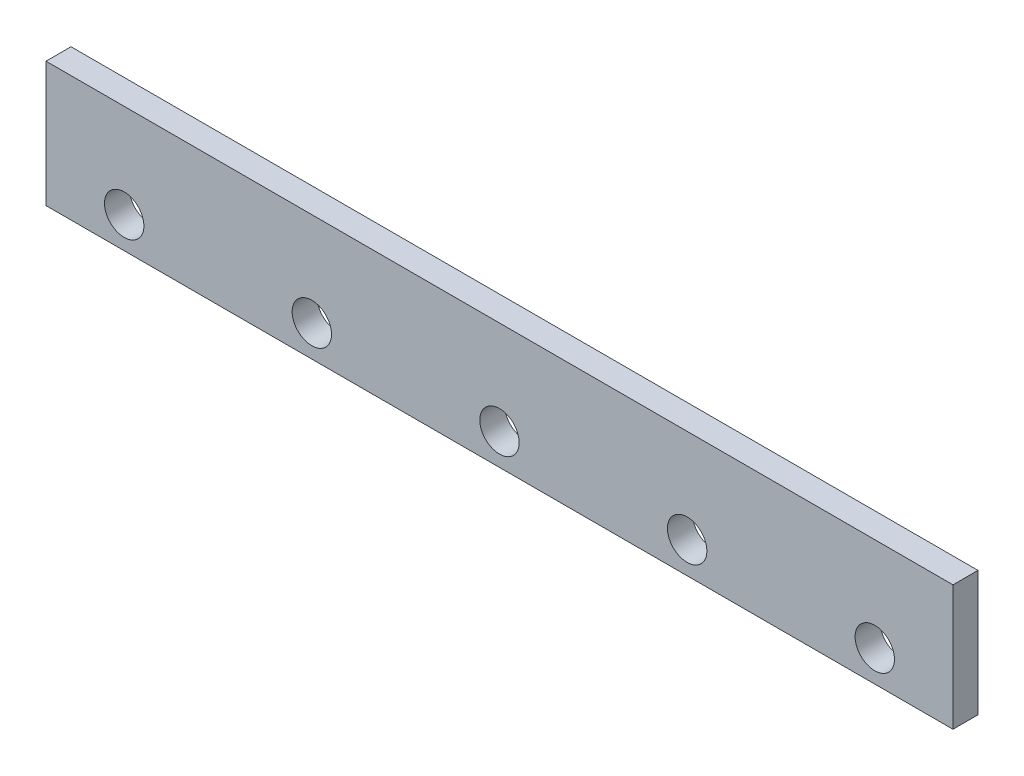
from build123d import *

# Parameters (mm, degrees)
SKETCH1_W           = 14732
SKETCH1_H           = 2032
SKETCH1_R           = 320.04
BOSS_EXTRUDE1_DEPTH = 406.4


with BuildPart() as part:
    # Sketch1 → Boss-Extrude1 (new body)
    with BuildSketch(Plane.XY):
        with Locations((7366, 1016)):
            Rectangle(SKETCH1_W, SKETCH1_H)
        with Locations((1270, 508)):
            Circle(SKETCH1_R, mode=Mode.SUBTRACT)
        with Locations((4318, 508)):
            Circle(SKETCH1_R, mode=Mode.SUBTRACT)
        with Locations((7366, 508)):
            Circle(SKETCH1_R, mode=Mode.SUBTRACT)
        with Locations((10414, 508)):
            Circle(SKETCH1_R, mode=Mode.SUBTRACT)
        with Locations((13462, 508)):
            Circle(SKETCH1_R, mode=Mode.SUBTRACT)
    extrude(amount=BOSS_EXTRUDE1_DEPTH)


solid = part.part
